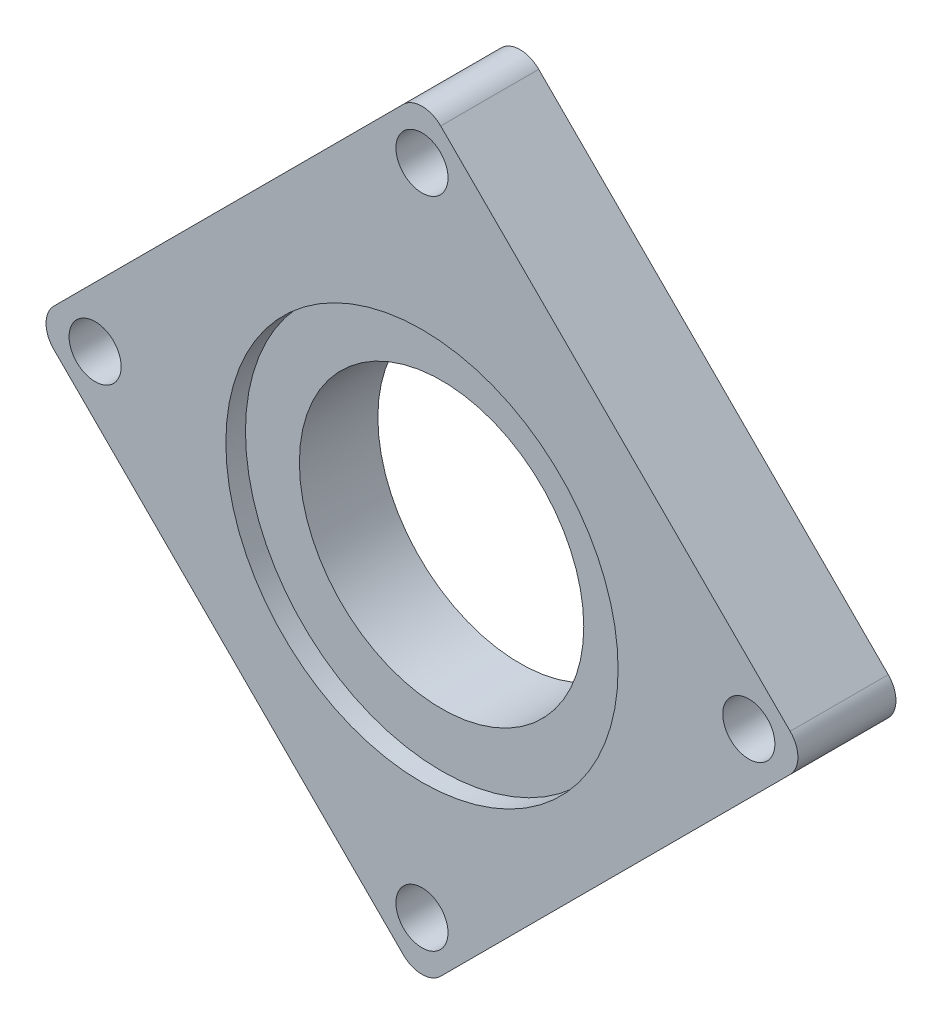
from build123d import *

# Parameters (mm, degrees)
SKETCH1_R           = 14.5
SKETCH1_R_2         = 2.655602963
BOSS_EXTRUDE1_DEPTH = 10
SKETCH2_R           = 20
CUT_EXTRUDE1_DEPTH  = 2


with BuildPart() as part:
    # Sketch1 → Boss-Extrude1 (new body)
    with BuildSketch(Plane.XY):
        with BuildLine():
            Line((96.456721684, 48.36687177), (64.849048565, 79.974544889))
            Line((64.849048565, 79.974544889), (60.818539912, 84.005053542))
            ThreePointArc((60.818539912, 84.005053542), (58.909351603, 84.795865233), (57.000163293, 84.005053542))
            Line((57.000163293, 84.005053542), (25.392490174, 52.397380423))
            Line((25.392490174, 52.397380423), (21.361981522, 48.36687177))
            ThreePointArc((21.361981522, 48.36687177), (20.571169831, 46.457683461), (21.361981522, 44.548495152))
            Line((21.361981522, 44.548495152), (52.969654641, 12.940822033))
            Line((52.969654641, 12.940822033), (57.000163293, 8.91031338))
            ThreePointArc((57.000163293, 8.91031338), (58.909351603, 8.119501689), (60.818539912, 8.91031338))
            Line((60.818539912, 8.91031338), (92.426213031, 40.517986499))
            Line((92.426213031, 40.517986499), (96.456721684, 44.548495152))
            ThreePointArc((96.456721684, 44.548495152), (97.247533374, 46.457683461), (96.456721684, 48.36687177))
        make_face()
        with Locations((58.909351603, 45.077265813)):
            Circle(SKETCH1_R, mode=Mode.SUBTRACT)
        with Locations((58.909351603, 13.124669796)):
            Circle(SKETCH1_R_2, mode=Mode.SUBTRACT)
        with Locations((92.242365268, 46.457683461)):
            Circle(SKETCH1_R_2, mode=Mode.SUBTRACT)
        with Locations((58.909351603, 79.790697126)):
            Circle(SKETCH1_R_2, mode=Mode.SUBTRACT)
        with Locations((25.576337937, 46.457683461)):
            Circle(SKETCH1_R_2, mode=Mode.SUBTRACT)
    extrude(amount=BOSS_EXTRUDE1_DEPTH)

    # Sketch2 → Cut-Extrude1 (cut)
    with BuildSketch(Plane.XY.offset(10)):
        with Locations((58.909351603, 45.077265813)):
            Circle(SKETCH2_R)
    extrude(amount=-CUT_EXTRUDE1_DEPTH, mode=Mode.SUBTRACT)


solid = part.part
